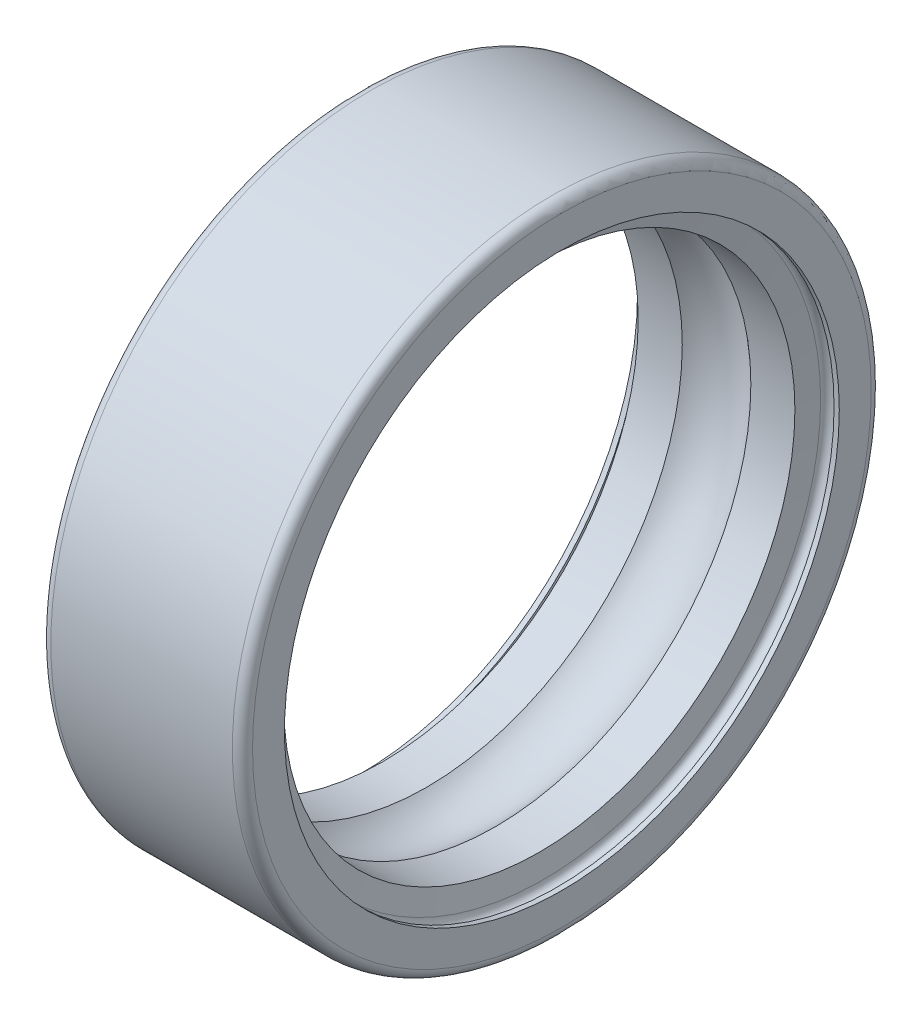
from build123d import *


with BuildPart() as part:
    # Sketch1 → Revolve1 (revolve)
    with BuildSketch(Plane.XY, mode=Mode.PRIVATE) as revolve1_sk:
        with BuildLine():
            Line((0, 9.2), (0, 8.25))
            Line((0, 8.25), (0.155555556, 8.25))
            ThreePointArc((0.155555556, 8.25), (0.355555556, 8.45), (0.555555556, 8.25))
            Line((0.555555556, 8.25), (0.670168093, 7.6))
            Line((0.670168093, 7.6), (1.980196097, 7.6))
            ThreePointArc((1.980196097, 7.6), (3, 8), (4.019803903, 7.6))
            Line((4.019803903, 7.6), (5.329831907, 7.6))
            Line((5.329831907, 7.6), (5.444444444, 8.25))
            ThreePointArc((5.444444444, 8.25), (5.644444444, 8.45), (5.844444444, 8.25))
            Line((5.844444444, 8.25), (6, 8.25))
            Line((6, 8.25), (6, 9.2))
            ThreePointArc((6, 9.2), (5.912132034, 9.412132034), (5.7, 9.5))
            Line((5.7, 9.5), (0.3, 9.5))
            ThreePointArc((0.3, 9.5), (0.087867966, 9.412132034), (0, 9.2))
        make_face()
    revolve(revolve1_sk.sketch.rotate(Axis((5.7, 0, 0), (-1, 0, 0)), 90), axis=Axis((5.7, 0, 0), (-1, 0, 0)))  # turned: the seam where the file's is


solid = part.part
